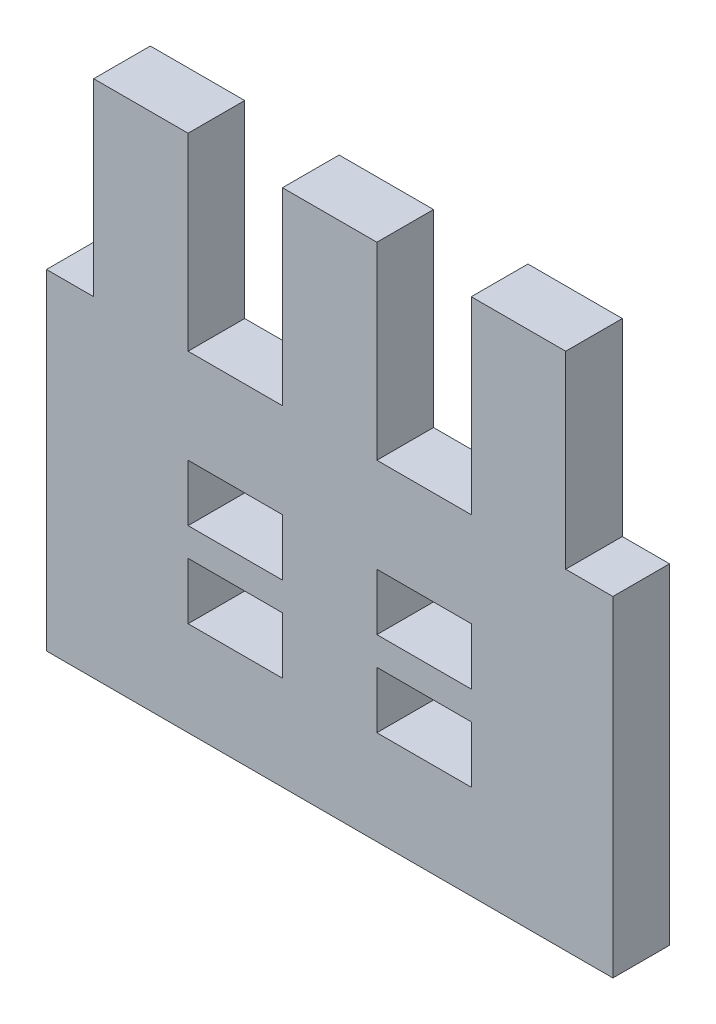
from build123d import *

# Parameters (mm, degrees)
ESQUISSE1_W        = 5
ESQUISSE1_H        = 3
BOSS_EXTRU_1_DEPTH = 3
ESQUISSE2_W        = 2.5
ESQUISSE2_H        = 7.5
BOSS_EXTRU_2_DEPTH = 3


with BuildPart() as part:
    # Esquisse1 → Boss.-Extru.1 (new body)
    with BuildSketch(Plane.XY):
        Polygon((-117.151475887, 41.372526747), (-117.151475887, 51.372526747), (-122.151475887, 51.372526747), (-122.151475887, 41.372526747), (-127.151475887, 41.372526747), (-127.151475887, 51.372526747), (-132.151475887, 51.372526747), (-132.151475887, 41.372526747), (-134.651475887, 41.372526747), (-134.651475887, 36.372526747), (-132.151475887, 36.372526747), (-132.151475887, 33.372526747), (-134.651475887, 33.372526747), (-134.651475887, 31.872526747), (-132.151475887, 31.872526747), (-132.151475887, 28.872526747), (-134.651475887, 28.872526747), (-134.651475887, 23.872526747), (-104.651475887, 23.872526747), (-104.651475887, 28.872526747), (-107.151475887, 28.872526747), (-107.151475887, 31.872526747), (-104.651475887, 31.872526747), (-104.651475887, 33.372526747), (-107.151475887, 33.372526747), (-107.151475887, 36.372526747), (-104.651475887, 36.372526747), (-104.651475887, 41.372526747), (-107.151475887, 41.372526747), (-107.151475887, 51.372526747), (-112.151475887, 51.372526747), (-112.151475887, 41.372526747), align=None)
        with Locations((-114.651475887, 30.372526747)):
            Rectangle(ESQUISSE1_W, ESQUISSE1_H, mode=Mode.SUBTRACT)
        with Locations((-124.651475887, 30.372526747)):
            Rectangle(ESQUISSE1_W, ESQUISSE1_H, mode=Mode.SUBTRACT)
        with Locations((-114.651475887, 34.872526747)):
            Rectangle(ESQUISSE1_W, ESQUISSE1_H, mode=Mode.SUBTRACT)
        with Locations((-124.651475887, 34.872526747)):
            Rectangle(ESQUISSE1_W, ESQUISSE1_H, mode=Mode.SUBTRACT)
    extrude(amount=BOSS_EXTRU_1_DEPTH)

    # Esquisse2 → Boss.-Extru.2 (add)
    with BuildSketch(Plane(origin=(0, 0, 0), x_dir=(-1, 0, 0), z_dir=(0, 0, -1))):
        with Locations((133.401475887, 32.622526747)):
            Rectangle(ESQUISSE2_W, ESQUISSE2_H)
        with Locations((105.901475887, 32.622526747)):
            Rectangle(ESQUISSE2_W, ESQUISSE2_H)
    extrude(amount=-BOSS_EXTRU_2_DEPTH)


solid = part.part
